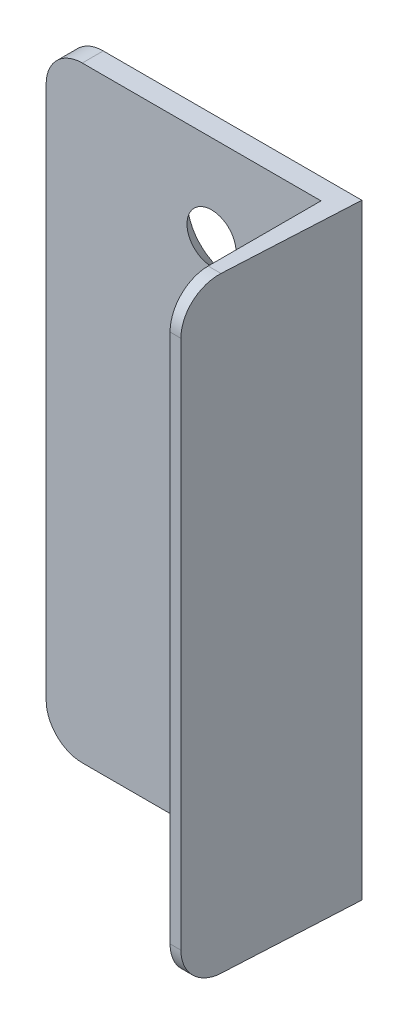
from build123d import *

# Parameters (mm, degrees)
BOSS_EXTRUDE1_DEPTH                            = 2.9
SKETCH2_W                                      = 2.75
SKETCH2_H                                      = 83.9
BOSS_EXTRUDE2_DEPTH                            = 20.9
CUT_EXTRUDE1_DEPTH                             = 27.75
CSK_FOR_M6_FLAT_HEAD_MACHINE_SCREW1_AT_2_COUNT = 2
CSK_FOR_M6_FLAT_HEAD_MACHINE_SCREW1_AT_2_PITCH = 59.791303716
SKETCH8_W                                      = 41.834673512
SKETCH8_H                                      = 83.9
CUT_REVOLVE4_ANGLE                             = 3


with BuildPart() as part:
    # Sketch1 → Boss-Extrude1 (new body)
    with BuildSketch(Plane.XY):
        with BuildLine():
            Line((-15.4, -41.95), (20.4, -41.95))
            Line((20.4, -41.95), (20.4, 41.95))
            Line((20.4, 41.95), (-15.4, 41.95))
            ThreePointArc((-15.4, 41.95), (-18.935533906, 40.485533906), (-20.4, 36.95))
            Line((-20.4, 36.95), (-20.4, -36.95))
            ThreePointArc((-20.4, -36.95), (-18.935533906, -40.485533906), (-15.4, -41.95))
        make_face()
    extrude(amount=BOSS_EXTRUDE1_DEPTH)

    # Sketch2 → Boss-Extrude2 (add)
    with BuildSketch(Plane.XY.offset(2.9)):
        with Locations((19.025, 0)):
            Rectangle(SKETCH2_W, SKETCH2_H)
    extrude(amount=BOSS_EXTRUDE2_DEPTH)

    # Sketch4 → Cut-Extrude1 (cut)
    with BuildSketch(Plane(origin=(20.4, 0, 0), x_dir=(0, 0, -1), z_dir=(1, 0, 0))):
        with BuildLine():
            Line((-23.8, 36.676506119), (-23.8, 41.95))
            Line((-23.8, 41.95), (-18.526506119, 41.95))
            ThreePointArc((-18.526506119, 41.95), (-22.255429403, 40.405429403), (-23.8, 36.676506119))
        make_face()
        with BuildLine():
            Line((-23.8, -41.95), (-23.8, -36.676506119))
            ThreePointArc((-23.8, -36.676506119), (-22.255429403, -40.405429403), (-18.526506119, -41.95))
            Line((-18.526506119, -41.95), (-23.8, -41.95))
        make_face()
    extrude(amount=-CUT_EXTRUDE1_DEPTH, mode=Mode.SUBTRACT)

    # Sketch6 → CSK for M6 Flat Head Machine Screw1 (revolve, cut)
    with BuildSketch(Plane(origin=(2.5, 29.895651858, 0), x_dir=(0, 1, 0), z_dir=(1, 0, 0))):
        Polygon((0, 0), (0, 2.9), (3.3, 2.9), (3.3, 3), (6.3, 0), align=None)
    csk_for_m6_flat_head_machine_screw1 = revolve(axis=Axis((2.5, 29.895651858, -6.35), (0, 0, 1)), mode=Mode.SUBTRACT)

    # CSK for M6 Flat Head Machine Screw1 at 2: CSK for M6 Flat Head Machine Screw1 ×2
    with Locations(*[(0, -i * CSK_FOR_M6_FLAT_HEAD_MACHINE_SCREW1_AT_2_PITCH, 0) for i in range(1, CSK_FOR_M6_FLAT_HEAD_MACHINE_SCREW1_AT_2_COUNT)]):
        add(csk_for_m6_flat_head_machine_screw1, mode=Mode.SUBTRACT)

    # Sketch8 → Cut-Revolve4 (revolve, cut)
    with BuildSketch(Plane(origin=(20.4, 0, 0), x_dir=(0, 0, -1), z_dir=(1, 0, 0))):
        with Locations((-20.917336756, 0)):
            Rectangle(SKETCH8_W, SKETCH8_H)
    revolve(axis=Axis((20.4, -41.95, 0), (0, -1, 0)), revolution_arc=CUT_REVOLVE4_ANGLE, mode=Mode.SUBTRACT)


solid = part.part
